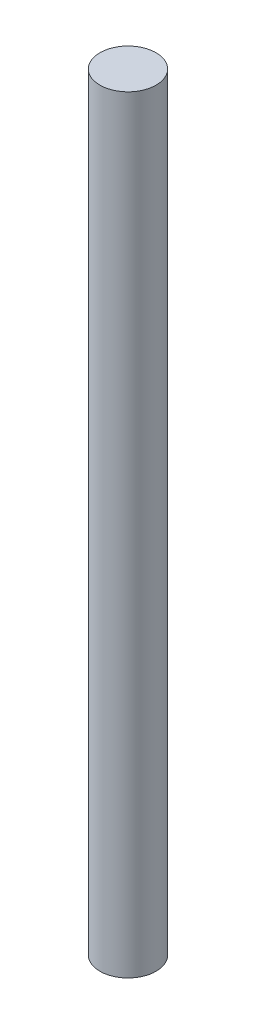
from build123d import *

# Parameters (mm, degrees)
SKETCH1_R           = 3
BOSS_EXTRUDE1_DEPTH = 82


with BuildPart() as part:
    # Sketch1 → Boss-Extrude1 (new body)
    with BuildSketch(Plane(origin=(0, 0, 0), x_dir=(1, 0, 0), z_dir=(0, 1, 0))):
        Circle(SKETCH1_R)
    extrude(amount=BOSS_EXTRUDE1_DEPTH)


solid = part.part
